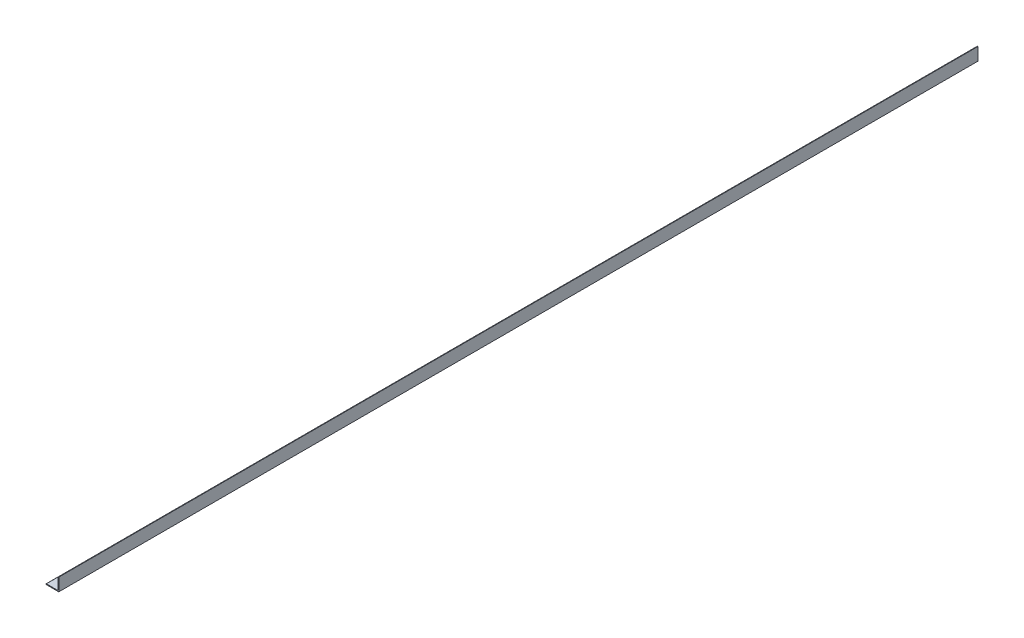
from build123d import *

# Parameters (mm, degrees)
BOSS_EXTRUDE1_DEPTH     = 914.4
F_1_4_20_TAPPED_HOLE1_D = 5.1054
CUT_EXTRUDE1_DEPTH      = 915.798166349


with BuildPart() as part:
    # Sketch2 → Boss-Extrude1 (new, symmetric)
    with BuildSketch(Plane.XY):
        with BuildLine():
            Line((-12.7, -12.7), (12.7, -12.7))
            Line((12.7, -12.7), (12.7, 12.7))
            Line((12.7, 12.7), (11.90625, 12.7))
            ThreePointArc((11.90625, 12.7), (11.344983992, 12.467516008), (11.1125, 11.90625))
            Line((11.1125, 11.90625), (11.1125, -9.5377))
            ThreePointArc((11.1125, -9.5377), (10.651251759, -10.651251759), (9.5377, -11.1125))
            Line((9.5377, -11.1125), (-11.90625, -11.1125))
            ThreePointArc((-11.90625, -11.1125), (-12.467516008, -11.344983992), (-12.7, -11.90625))
            Line((-12.7, -11.90625), (-12.7, -12.7))
        make_face()
    extrude(amount=BOSS_EXTRUDE1_DEPTH, both=True)

    # 1/4-20 Tapped Hole1 (through all)
    with Locations(Plane(origin=(0, -11.1125, 0), x_dir=(1, 0, 0), z_dir=(0, 1, 0))):
        with Locations((-1.5875, -661.924), (-1.5875, -206.248), (-1.5875, 705.104), (-1.5875, 249.428)):
            Hole(F_1_4_20_TAPPED_HOLE1_D / 2)

    # Sketch5 → Cut-Extrude1 (cut, through all)
    with BuildSketch(Plane(origin=(0, -11.1125, 0), x_dir=(1, 0, 0), z_dir=(0, 1, 0))):
        with BuildLine():
            Line((1.4605, -701.675), (1.4605, -720.725))
            ThreePointArc((1.4605, -720.725), (-1.5875, -723.773), (-4.6355, -720.725))
            Line((-4.6355, -720.725), (-4.6355, -701.675))
            ThreePointArc((-4.6355, -701.675), (-1.5875, -698.627), (1.4605, -701.675))
        make_face()
        with BuildLine():
            Line((1.4605, -285.75), (1.4605, -304.8))
            ThreePointArc((1.4605, -304.8), (-1.5875, -307.848), (-4.6355, -304.8))
            Line((-4.6355, -304.8), (-4.6355, -285.75))
            ThreePointArc((-4.6355, -285.75), (-1.5875, -282.702), (1.4605, -285.75))
        make_face()
        with BuildLine():
            Line((1.4605, 317.5), (1.4605, 336.55))
            ThreePointArc((1.4605, 336.55), (-1.5875, 339.598), (-4.6355, 336.55))
            Line((-4.6355, 336.55), (-4.6355, 317.5))
            ThreePointArc((-4.6355, 317.5), (-1.5875, 314.452), (1.4605, 317.5))
        make_face()
        with BuildLine():
            Line((1.4605, 717.55), (1.4605, 736.6))
            ThreePointArc((1.4605, 736.6), (-1.5875, 739.648), (-4.6355, 736.6))
            Line((-4.6355, 736.6), (-4.6355, 717.55))
            ThreePointArc((-4.6355, 717.55), (-1.5875, 714.502), (1.4605, 717.55))
        make_face()
    extrude(amount=-CUT_EXTRUDE1_DEPTH, mode=Mode.SUBTRACT)


solid = part.part
